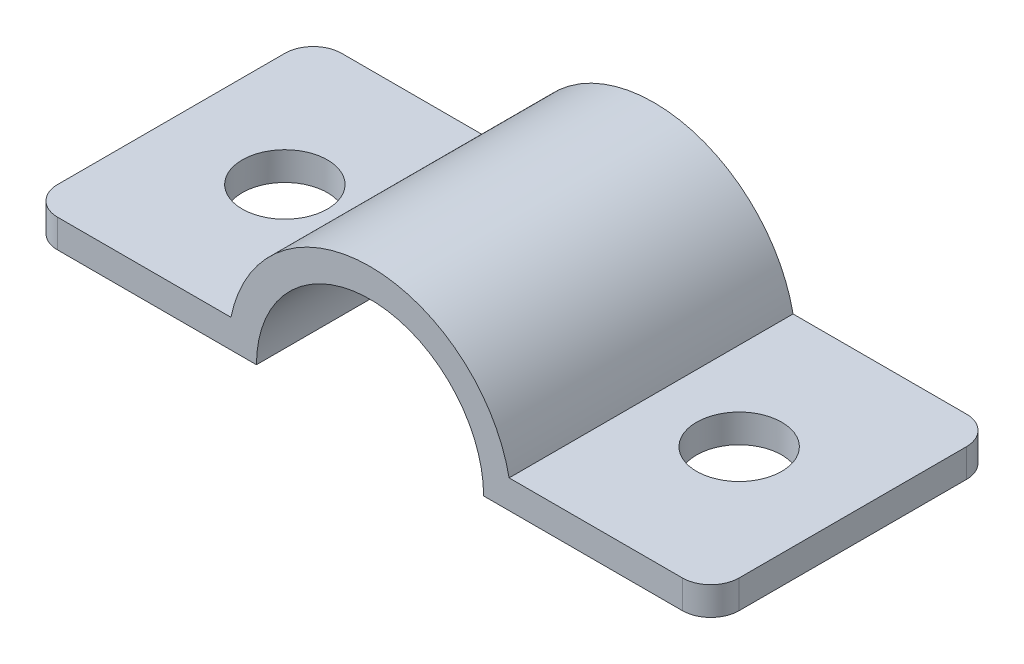
from build123d import *

# Parameters (mm, degrees)
BOSS_EXTRUDE1_DEPTH = 5
FILLET1_R           = 1
SKETCH2_R           = 1.5
CUT_EXTRUDE1_DEPTH  = 10


with BuildPart() as part:
    # Sketch1 → Boss-Extrude1 (new body, symmetric)
    with BuildSketch(Plane.XY):
        with BuildLine():
            Line((4, 0), (12, 0))
            Line((12, 0), (12, 1))
            Line((12, 1), (4.898979486, 1))
            ThreePointArc((4.898979486, 1), (0, 5), (-4.898979486, 1))
            Line((-4.898979486, 1), (-12, 1))
            Line((-12, 1), (-12, 0))
            Line((-12, 0), (-4, 0))
            ThreePointArc((-4, 0), (0, 4), (4, 0))
        make_face()
    extrude(amount=BOSS_EXTRUDE1_DEPTH, both=True)

    # Fillet1
    fillet1_edges = [part.edges().sort_by_distance(p)[0] for p in [
        (-12, 0.5, -5),
        (-12, 0.5, 5),
        (12, 0.5, 5),
        (12, 0.5, -5),
    ]]
    fillet(fillet1_edges, radius=FILLET1_R)

    # Sketch2 → Cut-Extrude1 (cut)
    with BuildSketch(Plane(origin=(0, 1, 0), x_dir=(1, 0, 0), z_dir=(0, 1, 0))):
        with Locations((-8, 0)):
            Circle(SKETCH2_R)
        with Locations((8, 0)):
            Circle(SKETCH2_R)
    extrude(amount=-CUT_EXTRUDE1_DEPTH, mode=Mode.SUBTRACT)


solid = part.part
